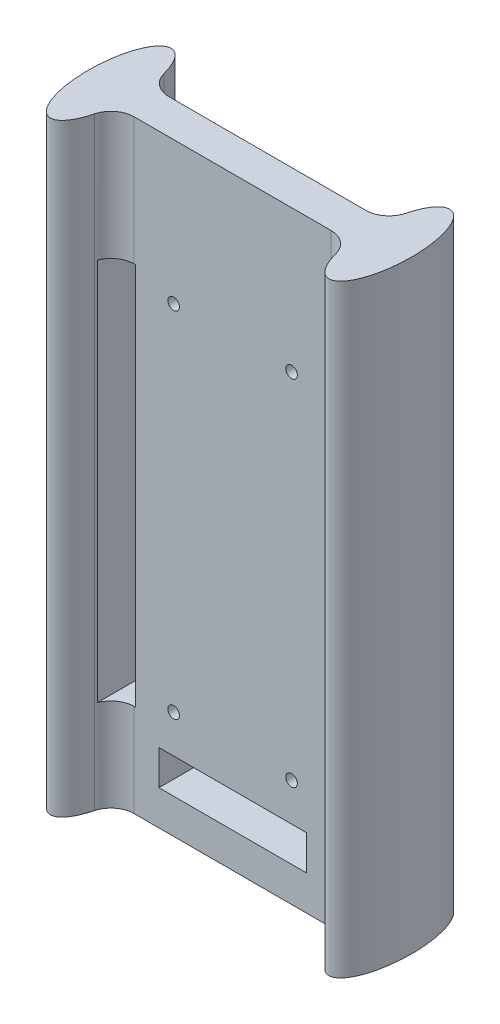
from build123d import *

# Parameters (mm, degrees)
BOSS_EXTRUDE1_DEPTH         = 130
FILLET1_R                   = 5
SKETCH3_W                   = 5
SKETCH3_H                   = 82.55
SKETCH3_W_2                 = 31.75
SKETCH3_H_2                 = 7.5
CUT_EXTRUDE2_DEPTH          = 10.2500001
CUT_EXTRUDE2_DEPTH_BACK     = 17.7500001
TAP_DRILL_FOR_M3X0_5_TAP1_D = 2.5


with BuildPart() as part:
    # Sketch1 → Boss-Extrude1 (new body)
    with BuildSketch(Plane(origin=(0, 0, 0), x_dir=(1, 0, 0), z_dir=(0, 1, 0))):
        with BuildLine():
            add(Edge.make_bspline(
                [(25.356166305, 3.75), (24.934680795, 0), (25.356166305, -3.75)],
                knots=[1.278176641, 1.278176641, 1.278176641, 1.863416012, 1.863416012, 1.863416012], degree=2, weights=[1, 0.957491483, 1]))
            Line((25.356166305, 3.75), (-25.356166305, 3.75))
            add(Edge.make_bspline(
                [(-25.356166305, -3.75), (-24.934680795, 0), (-25.356166305, 3.75)],
                knots=[1.278176641, 1.278176641, 1.278176641, 1.863416012, 1.863416012, 1.863416012], degree=2, weights=[1, 0.957491483, 1]))
            Line((-25.356166305, -3.75), (25.356166305, -3.75))
        make_face()
        with BuildLine():
            add(Edge.make_bspline(
                [(-25.356166305, -3.75), (-24.934680795, 0), (-25.356166305, 3.75)],
                knots=[1.278176641, 1.278176641, 1.278176641, 1.863416012, 1.863416012, 1.863416012], degree=2, weights=[1, 0.957491483, 1]))
            Line((-25.356166305, 3.75), (-30, 3.75))
            Line((-30, 3.75), (-30, -3.75))
            Line((-30, -3.75), (-25.356166305, -3.75))
        make_face()
        with BuildLine():
            Line((-30, 3.75), (-25.356166305, 3.75))
            add(Edge.make_bspline(
                [(-25.356166305, 3.75), (-28.138876861, 28.508062419), (-33.892803395, 7.75403121), (-39.646729928, -13), (-30, -13)],
                knots=[1.863416012, 1.863416012, 1.863416012, 4.07330066, 4.07330066, 6.283185307, 6.283185307, 6.283185307], degree=2, weights=[1, 0.449185964, 1, 0.449185964, 1]))
            add(Edge.make_bspline(
                [(-30, -13), (-26.395830565, -13), (-25.356166305, -3.75)],
                knots=[0, 0, 0, 1.278176641, 1.278176641, 1.278176641], degree=2, weights=[1, 0.802639875, 1]))
            Line((-25.356166305, -3.75), (-30, -3.75))
            Line((-30, -3.75), (-30, 3.75))
        make_face()
        with BuildLine():
            Line((30, -3.75), (30, 3.75))
            Line((30, 3.75), (25.356166305, 3.75))
            add(Edge.make_bspline(
                [(25.356166305, 3.75), (24.934680795, 0), (25.356166305, -3.75)],
                knots=[1.278176641, 1.278176641, 1.278176641, 1.863416012, 1.863416012, 1.863416012], degree=2, weights=[1, 0.957491483, 1]))
            Line((25.356166305, -3.75), (30, -3.75))
        make_face()
        with BuildLine():
            Line((25.356166305, 3.75), (30, 3.75))
            Line((30, 3.75), (30, -3.75))
            Line((30, -3.75), (25.356166305, -3.75))
            add(Edge.make_bspline(
                [(25.356166305, -3.75), (28.138876861, -28.508062419), (33.892803395, -7.75403121), (39.646729928, 13), (30, 13)],
                knots=[1.863416012, 1.863416012, 1.863416012, 4.07330066, 4.07330066, 6.283185307, 6.283185307, 6.283185307], degree=2, weights=[1, 0.449185964, 1, 0.449185964, 1]))
            add(Edge.make_bspline(
                [(30, 13), (26.395830565, 13), (25.356166305, 3.75)],
                knots=[0, 0, 0, 1.278176641, 1.278176641, 1.278176641], degree=2, weights=[1, 0.802639875, 1]))
        make_face()
    extrude(amount=BOSS_EXTRUDE1_DEPTH)

    # Fillet1
    fillet1_edges = [part.edges().sort_by_distance(p)[0] for p in [
        (-25.356166305, 65, -3.75),
        (25.356166305, 65, -3.75),
        (25.356166305, 65, 3.75),
        (-25.356166305, 65, 3.75),
    ]]
    fillet(fillet1_edges, radius=FILLET1_R)

    # Sketch3 → Cut-Extrude2 (cut, two sides)
    with BuildSketch(Plane(origin=(0, 0, -3.75), x_dir=(-1, 0, 0), z_dir=(0, 0, -1))) as cut_extrude2_sk:
        with Locations((23.375, 61.275)):
            Rectangle(SKETCH3_W, SKETCH3_H)
        with Locations((0, 11.25)):
            Rectangle(SKETCH3_W_2, SKETCH3_H_2)
    extrude(amount=CUT_EXTRUDE2_DEPTH, mode=Mode.SUBTRACT)
    extrude(cut_extrude2_sk.sketch, amount=-CUT_EXTRUDE2_DEPTH_BACK, mode=Mode.SUBTRACT)

    # Tap Drill for M3x0.5 Tap1 (through all)
    with Locations(Plane(origin=(12.7, 99.375, -3.75), x_dir=(-1, 0, 0), z_dir=(0, 0, -1))):
        with Locations((0, 0), (25.4, 0), (25.4, -76.2), (0, -76.2)):
            Hole(TAP_DRILL_FOR_M3X0_5_TAP1_D / 2)


solid = part.part
